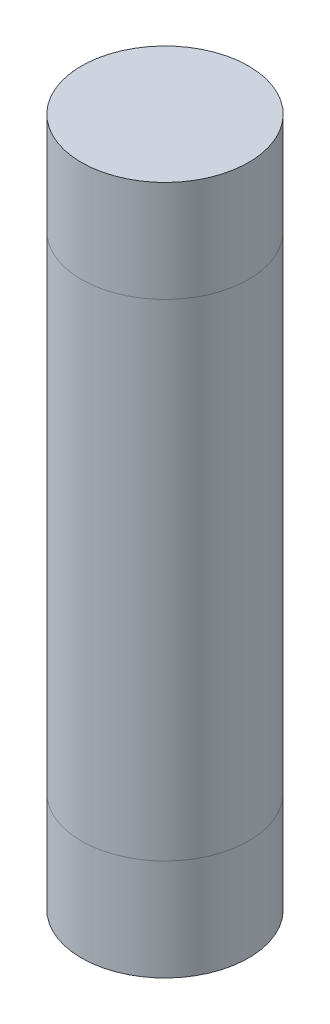
from build123d import *

# Parameters (mm, degrees)
SKETCH1_R           = 8.25
BOSS_EXTRUDE1_DEPTH = 10
SKETCH2_R           = 8.25
BOSS_EXTRUDE2_DEPTH = 48
SKETCH3_R           = 8.25
BOSS_EXTRUDE3_DEPTH = 10


with BuildPart() as part:
    # Sketch1 → Boss-Extrude1 (new body)
    with BuildSketch(Plane(origin=(0, 0, 0), x_dir=(1, 0, 0), z_dir=(0, 1, 0))):
        Circle(SKETCH1_R)
    extrude(amount=BOSS_EXTRUDE1_DEPTH)


with BuildPart() as body_2:
    # Sketch2 → Boss-Extrude2 (new body)
    with BuildSketch(Plane(origin=(0, 10, 0), x_dir=(1, 0, 0), z_dir=(0, 1, 0))):
        Circle(SKETCH2_R)
    extrude(amount=BOSS_EXTRUDE2_DEPTH)


with BuildPart() as body_3:
    # Sketch3 → Boss-Extrude3 (new body)
    with BuildSketch(Plane(origin=(0, 58, 0), x_dir=(1, 0, 0), z_dir=(0, 1, 0))):
        Circle(SKETCH3_R)
    extrude(amount=BOSS_EXTRUDE3_DEPTH)


solid = Compound([part.part, body_2.part, body_3.part])
